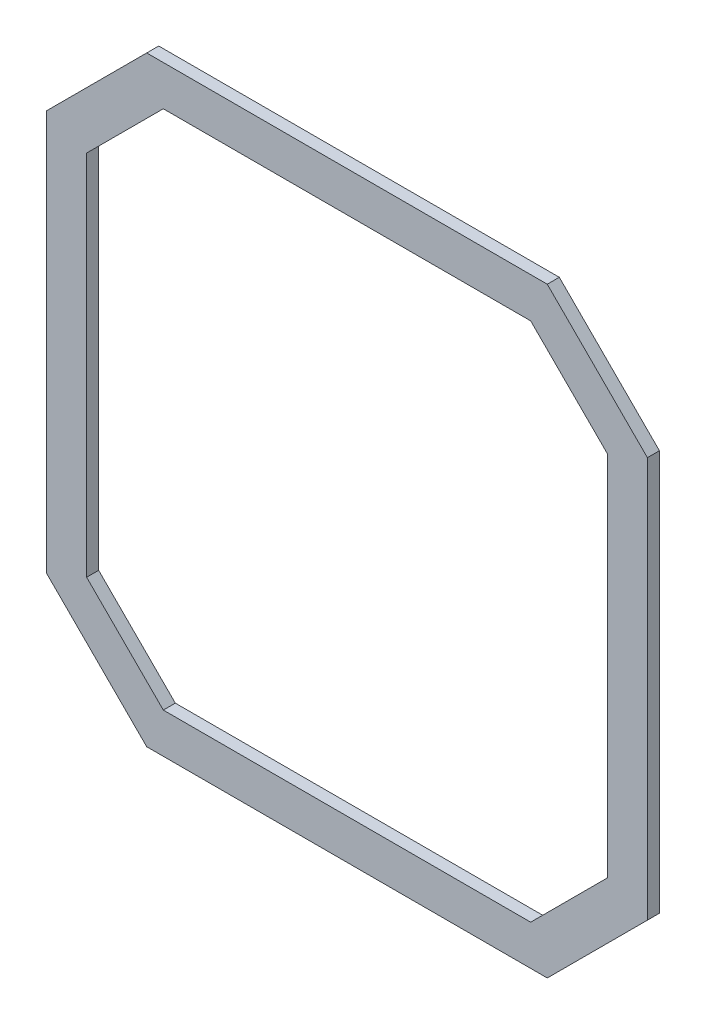
from build123d import *

# Parameters (mm, degrees)
BOSS_EXTRUDE1_DEPTH = 3


with BuildPart() as part:
    # Sketch1 → Boss-Extrude1 (new body)
    with BuildSketch(Plane.XY):
        Polygon((45.5, 78.667286245), (70.5, 53.667286245), (70.5, -46.332713755), (45.5, -71.332713755), (-54.5, -71.332713755), (-79.5, -46.332713755), (-79.5, 53.667286245), (-54.5, 78.667286245), align=None)
        Polygon((41.357864376, 68.667286245), (60.5, 49.525150622), (60.5, -42.190578131), (41.357864376, -61.332713755), (-50.357864376, -61.332713755), (-69.5, -42.190578131), (-69.5, 49.525150622), (-50.357864376, 68.667286245), align=None, mode=Mode.SUBTRACT)
    extrude(amount=BOSS_EXTRUDE1_DEPTH)


solid = part.part
